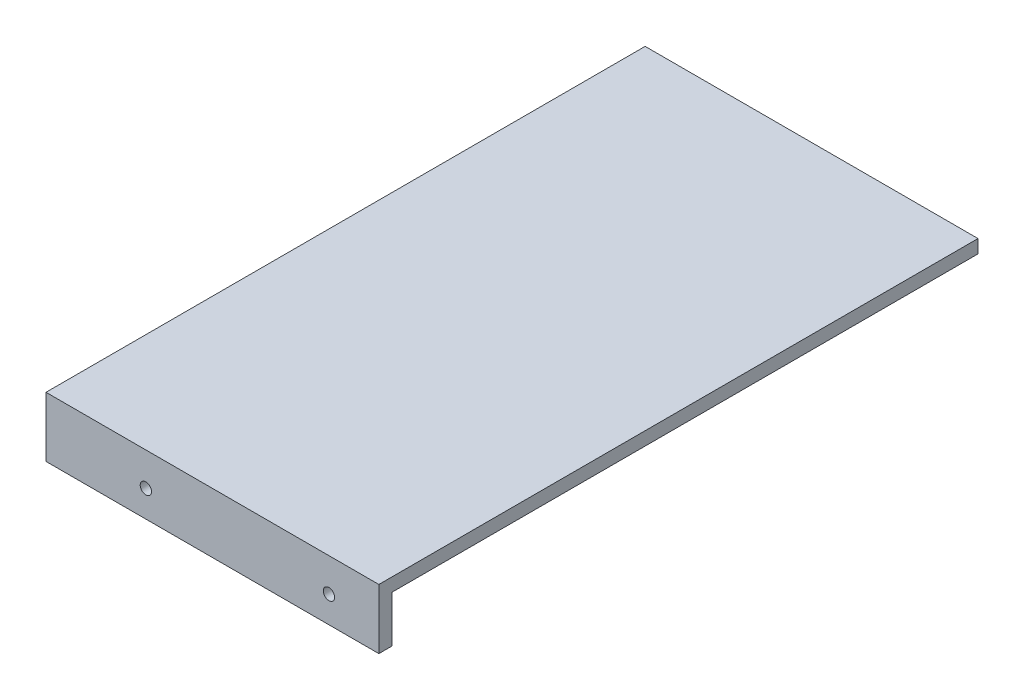
from build123d import *

# Parameters (mm, degrees)
SKETCH1_W           = 180
SKETCH1_H           = 18
SKETCH1_R           = 1.7
BOSS_EXTRUDE1_DEPTH = 4
SKETCH2_W           = 100
SKETCH2_H           = 18
SKETCH2_R           = 1.7
BOSS_EXTRUDE2_DEPTH = 4
SKETCH3_W           = 96
SKETCH3_H           = 4
BOSS_EXTRUDE3_DEPTH = 176


with BuildPart() as part:
    # Sketch1 → Boss-Extrude1 (new body)
    with BuildSketch(Plane(origin=(-1647.169528543, 0, 0), x_dir=(0, 0, -1), z_dir=(1, 0, 0))):
        with Locations((-1279.825666692, 760.849345995)):
            Rectangle(SKETCH1_W, SKETCH1_H)
        with Locations((-1219.825666692, 759.849345995)):
            Circle(SKETCH1_R, mode=Mode.SUBTRACT)
        with Locations((-1339.825666692, 759.849345995)):
            Circle(SKETCH1_R, mode=Mode.SUBTRACT)
    extrude(amount=BOSS_EXTRUDE1_DEPTH)

    # Sketch2 → Boss-Extrude2 (add)
    with BuildSketch(Plane(origin=(0, 0, 1369.825666692), x_dir=(-1, 0, 0), z_dir=(0, 0, -1))):
        with Locations((1597.169528543, 760.849345995)):
            Rectangle(SKETCH2_W, SKETCH2_H)
        with Locations((1617.169528543, 759.849345995)):
            Circle(SKETCH2_R, mode=Mode.SUBTRACT)
        with Locations((1562.169528543, 759.849345995)):
            Circle(SKETCH2_R, mode=Mode.SUBTRACT)
    extrude(amount=BOSS_EXTRUDE2_DEPTH)

    # Sketch3 → Boss-Extrude3 (add)
    with BuildSketch(Plane(origin=(0, 0, 1365.825666692), x_dir=(-1, 0, 0), z_dir=(0, 0, -1))):
        with Locations((1595.169528543, 767.849345995)):
            Rectangle(SKETCH3_W, SKETCH3_H)
    extrude(amount=BOSS_EXTRUDE3_DEPTH)


solid = part.part
